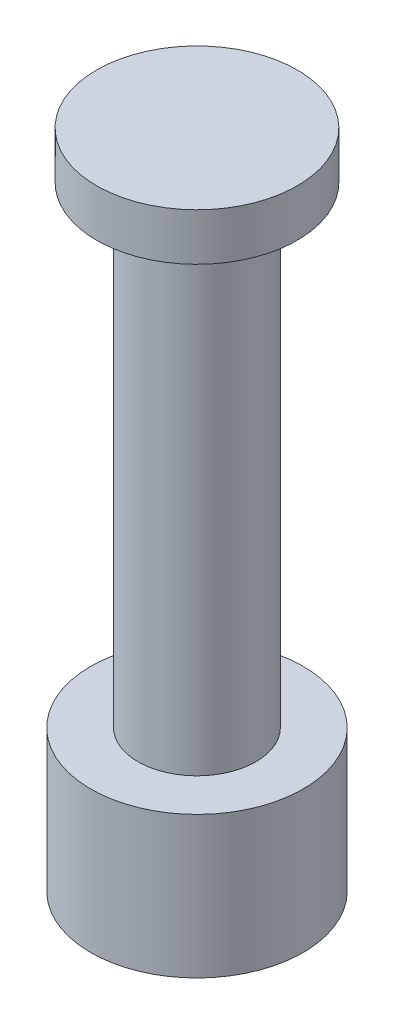
from build123d import *


with BuildPart() as part:
    # Sketch1 → Revolve1 (revolve)
    with BuildSketch(Plane.XY):
        Polygon((0, 14), (4.25, 14), (4.25, 12), (2.5, 12), (2.5, -8), (4.5, -8), (4.5, -14), (0, -14), align=None)
    revolve(axis=Axis((0, 14, 0), (0, -1, 0)))


solid = part.part
